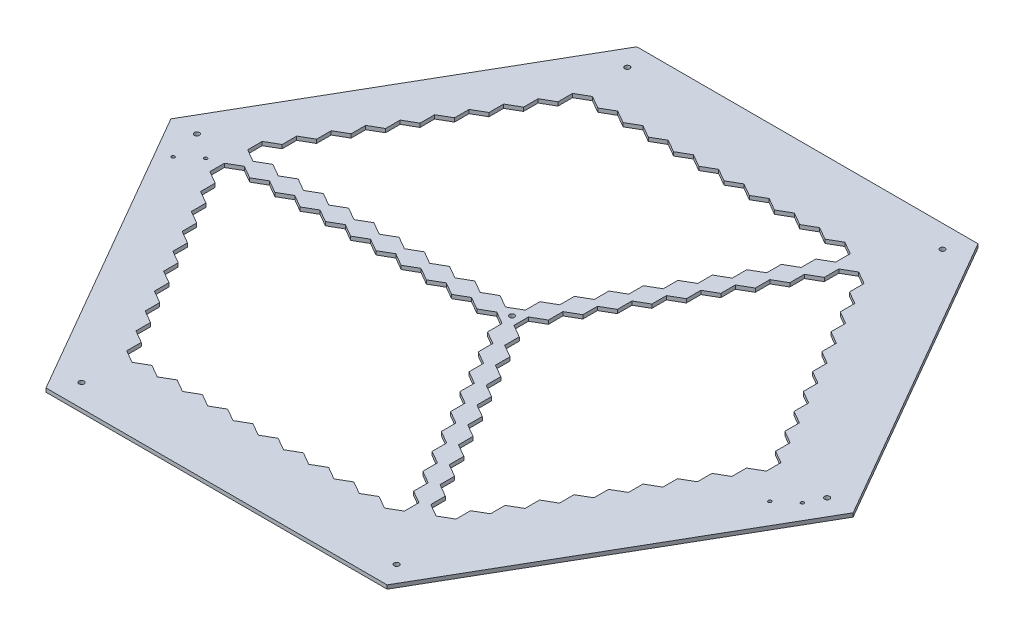
from build123d import *

# Parameters (mm, degrees)
BASE_DEPTH                     = 4.7625
BOTTOM_DISH_CUT_REACH          = 574.842
BOTTOM_DISH_PATTERN_COUNT      = 11
BOTTOM_DISH_PATTERN_PITCH      = 32.04
BOTTOM_DISH_PATTERN_COUNT_DIR2 = 10
BOTTOM_DISH_PATTERN_PITCH_DIR2 = 32.04
TOP_DISH_CUT_REACH             = 574.842
TOP_DISH_PATTERN_COUNT         = 11
TOP_DISH_PATTERN_PITCH         = 32.04
TOP_DISH_PATTERN_COUNT_DIR2    = 10
TOP_DISH_PATTERN_PITCH_DIR2    = 32.04
RIGHT_DISH_CUT_REACH           = 574.842
RIGHT_DISH_PATTERN_COUNT       = 10
RIGHT_DISH_PATTERN_PITCH       = 32.04
RIGHT_DISH_PATTERN_COUNT_DIR2  = 10
RIGHT_DISH_PATTERN_PITCH_DIR2  = 32.04
F_6_5_6_5_DIAMETER_HOLE1_D     = 6.5
F_4_0_4_DIAMETER_HOLE1_D       = 4


with BuildPart() as part:
    # Sketch1 → Base (new body)
    with BuildSketch(Plane(origin=(0, 0, 0), x_dir=(1, 0, 0), z_dir=(0, 1, 0))):
        Polygon((433.012701892, 0), (216.506350946, 375), (-216.506350946, 375), (-433.012701892, 0), (-216.506350946, -375), (216.506350946, -375), align=None)
    extrude(amount=BASE_DEPTH)

    # Sketch3 → Bottom Dish Cut (cut, up to next)
    with BuildSketch(Plane(origin=(0, 4.7625, 0), x_dir=(1, 0, 0), z_dir=(0, 1, 0)), mode=Mode.PRIVATE) as bottom_dish_cut_sk1:
        Polygon((-13.856406461, -5.5), (-29.877876431, -14.75), (-29.877876431, -33.25), (-13.856406461, -42.5), (2.165063509, -33.25), (2.165063509, -14.75), align=None)
    bottom_dish_cut_tool1 = extrude(bottom_dish_cut_sk1.sketch, amount=-BOTTOM_DISH_CUT_REACH, mode=Mode.PRIVATE) & part.part
    bottom_dish_cut = bottom_dish_cut_tool1.solids().sort_by_distance((-13.856406, 4.7625, 24))[0]
    add(bottom_dish_cut, mode=Mode.SUBTRACT)

    # Bottom Dish Pattern: Bottom Dish Cut 11 × 10
    with Locations(*[Vector(-1, 0, 0) * (i * BOTTOM_DISH_PATTERN_PITCH) + Vector(0.5000000000000011, 0, 0.866025403784438) * (j * BOTTOM_DISH_PATTERN_PITCH_DIR2) for i in range(BOTTOM_DISH_PATTERN_COUNT) for j in range(BOTTOM_DISH_PATTERN_COUNT_DIR2) if (i, j) != (0, 0)]):
        add(bottom_dish_cut, mode=Mode.SUBTRACT)

    # Sketch4 → Top Dish Cut (cut, up to next)
    with BuildSketch(Plane(origin=(0, 4.7625, 0), x_dir=(1, 0, 0), z_dir=(0, 1, 0)), mode=Mode.PRIVATE) as top_dish_cut_sk1:
        Polygon((-13.856406461, 42.5), (-29.877876431, 33.25), (-29.877876431, 14.75), (-13.856406461, 5.5), (2.165063509, 14.75), (2.165063509, 33.25), align=None)
    top_dish_cut_tool1 = extrude(top_dish_cut_sk1.sketch, amount=-TOP_DISH_CUT_REACH, mode=Mode.PRIVATE) & part.part
    top_dish_cut = top_dish_cut_tool1.solids().sort_by_distance((-13.856406, 4.7625, -24))[0]
    add(top_dish_cut, mode=Mode.SUBTRACT)

    # Top Dish Pattern: Top Dish Cut 11 × 10
    with Locations(*[Vector(-1, 0, 0) * (i * TOP_DISH_PATTERN_PITCH) + Vector(0.49999999999999895, 0, -0.8660254037844393) * (j * TOP_DISH_PATTERN_PITCH_DIR2) for i in range(TOP_DISH_PATTERN_COUNT) for j in range(TOP_DISH_PATTERN_COUNT_DIR2) if (i, j) != (0, 0)]):
        add(top_dish_cut, mode=Mode.SUBTRACT)

    # Sketch5 → Right Dish Cut (cut, up to next)
    with BuildSketch(Plane(origin=(0, 4.7625, 0), x_dir=(1, 0, 0), z_dir=(0, 1, 0)), mode=Mode.PRIVATE) as right_dish_cut_sk1:
        Polygon((27.712812921, 18.5), (11.691342951, 9.25), (11.691342951, -9.25), (27.712812921, -18.5), (43.734282891, -9.25), (43.734282891, 9.25), align=None)
    right_dish_cut_tool1 = extrude(right_dish_cut_sk1.sketch, amount=-RIGHT_DISH_CUT_REACH, mode=Mode.PRIVATE) & part.part
    right_dish_cut = right_dish_cut_tool1.solids().sort_by_distance((27.712813, 4.7625, 0))[0]
    add(right_dish_cut, mode=Mode.SUBTRACT)

    # Right Dish Pattern: Right Dish Cut 10 × 10
    with Locations(*[Vector(0.4999999999999989, 0, -0.8660254037844393) * (i * RIGHT_DISH_PATTERN_PITCH) + Vector(0.500000000000001, 0, 0.8660254037844382) * (j * RIGHT_DISH_PATTERN_PITCH_DIR2) for i in range(RIGHT_DISH_PATTERN_COUNT) for j in range(RIGHT_DISH_PATTERN_COUNT_DIR2) if (i, j) != (0, 0)]):
        add(right_dish_cut, mode=Mode.SUBTRACT)

    # Ø6.5 (6.5) Diameter Hole1 (through all)
    with Locations(Plane(origin=(0, 4.7625, 0), x_dir=(1, 0, 0), z_dir=(0, 1, 0))):
        with Locations((0, 0), (-400, 0), (-200, 346.410161514), (200, 346.410161514), (400, 0), (200, -346.410161514), (-200, -346.410161514)):
            Hole(F_6_5_6_5_DIAMETER_HOLE1_D / 2)

    # Ø4.0 (4) Diameter Hole1 (through all)
    with Locations(Plane(origin=(0, -9.525, 0), x_dir=(-1, 0, 0), z_dir=(0, -1, 0))):
        with Locations((-389.762701892, -21.272379971), (-367.537701892, -40.322379971), (367.537701892, -21.272379971), (389.762701892, -40.322379971)):
            Hole(F_4_0_4_DIAMETER_HOLE1_D / 2)


solid = part.part
